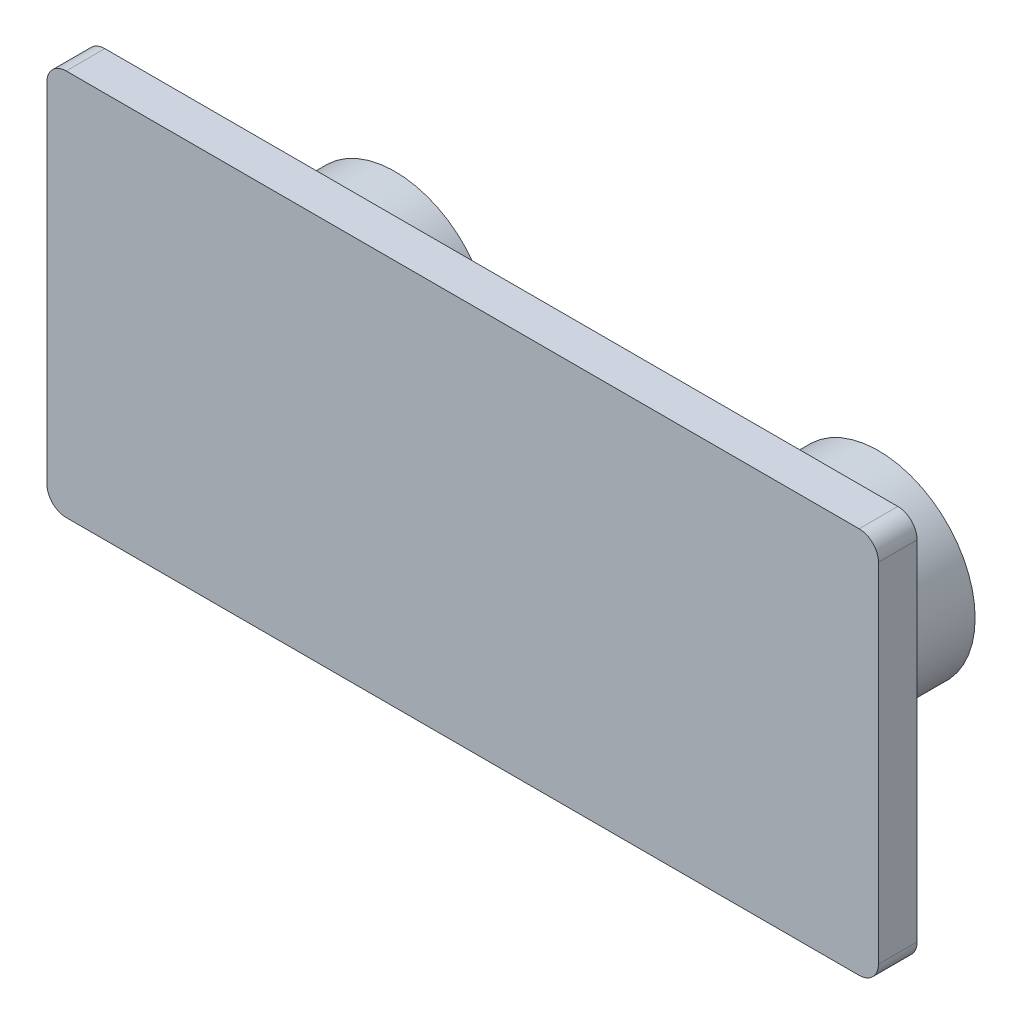
from build123d import *

# Parameters (mm, degrees)
SKETCH1_W           = 43
SKETCH1_H           = 20
BOSS_EXTRUDE1_DEPTH = 1
SKETCH2_R           = 5
BOSS_EXTRUDE2_DEPTH = 7
FILLET1_R           = 2
FILLET2_R           = 1


with BuildPart() as part:
    # Sketch1 → Boss-Extrude1 (new body, symmetric)
    with BuildSketch(Plane.XY):
        Rectangle(SKETCH1_W, SKETCH1_H)
    extrude(amount=BOSS_EXTRUDE1_DEPTH, both=True)

    # Sketch2 → Boss-Extrude2 (add)
    with BuildSketch(Plane.XY.offset(-1)):
        with Locations((-12.5, 0)):
            Circle(SKETCH2_R)
        with Locations((12.5, 0)):
            Circle(SKETCH2_R)
    extrude(amount=-BOSS_EXTRUDE2_DEPTH)

    # Fillet1
    fillet1_edges = [part.edges().sort_by_distance(p)[0] for p in [
        (-17.5, 0, -1),
        (7.5, 0, -1),
    ]]
    fillet(fillet1_edges, radius=FILLET1_R)

    # Fillet2
    fillet2_edges = [part.edges().sort_by_distance(p)[0] for p in [
        (21.5, -10, 0),
        (-21.5, -10, 0),
        (-21.5, 10, 0),
        (21.5, 10, 0),
    ]]
    fillet(fillet2_edges, radius=FILLET2_R)


solid = part.part
